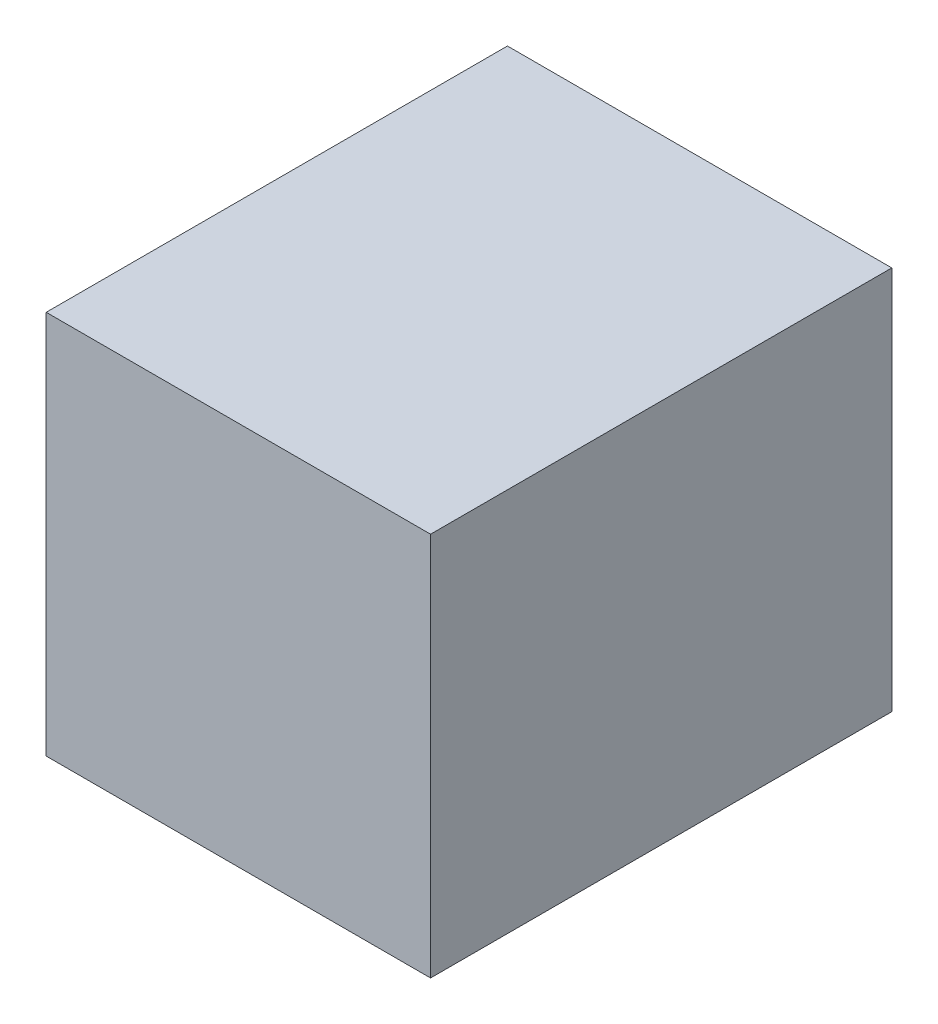
from build123d import *

# Parameters (mm, degrees)
SKETCH1_W           = 5
SKETCH1_H           = 5
BOSS_EXTRUDE1_DEPTH = 6


with BuildPart() as part:
    # Sketch1 → Boss-Extrude1 (new body)
    with BuildSketch(Plane.XY):
        Rectangle(SKETCH1_W, SKETCH1_H)
    extrude(amount=BOSS_EXTRUDE1_DEPTH)


solid = part.part
